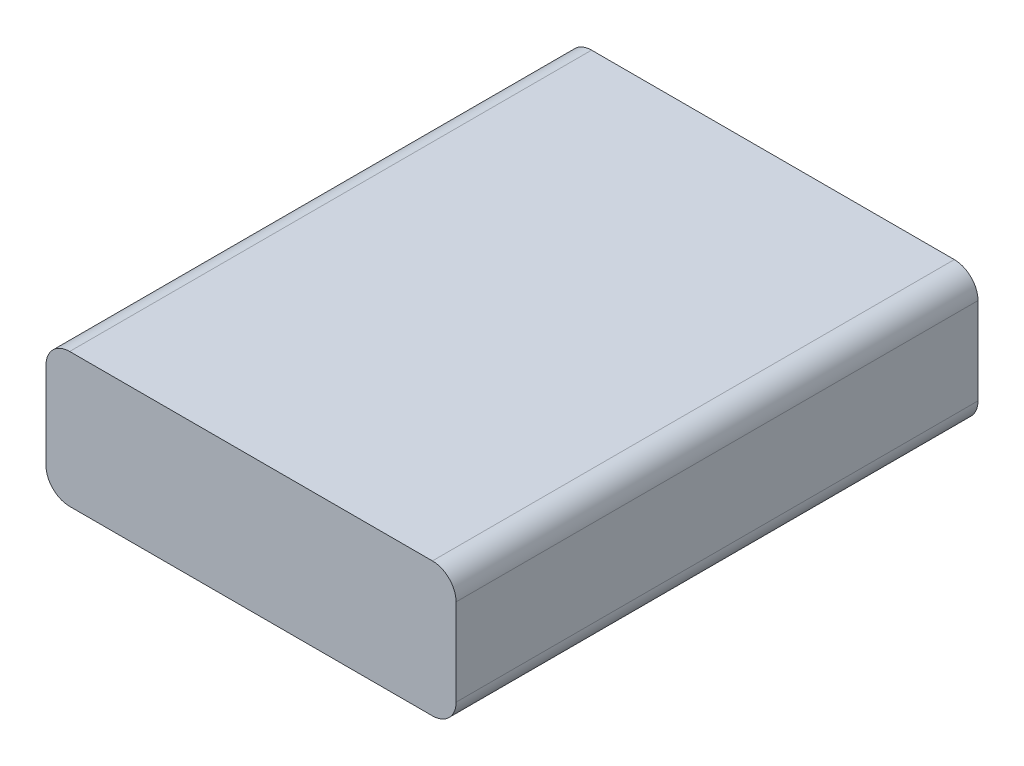
from build123d import *

# Parameters (mm, degrees)
BOSS_EXTRUDE1_DEPTH = 70


with BuildPart() as part:
    # Sketch1 → Boss-Extrude1 (new body)
    with BuildSketch(Plane.XY):
        with BuildLine():
            Line((-24.325, 0), (24.325, 0))
            ThreePointArc((24.325, 0), (26.57006403, 0.92993597), (27.5, 3.175))
            Line((27.5, 3.175), (27.5, 14.825))
            ThreePointArc((27.5, 14.825), (26.57006403, 17.07006403), (24.325, 18))
            Line((24.325, 18), (-24.325, 18))
            ThreePointArc((-24.325, 18), (-26.57006403, 17.07006403), (-27.5, 14.825))
            Line((-27.5, 14.825), (-27.5, 3.175))
            ThreePointArc((-27.5, 3.175), (-26.57006403, 0.92993597), (-24.325, 0))
        make_face()
    extrude(amount=BOSS_EXTRUDE1_DEPTH)


solid = part.part
